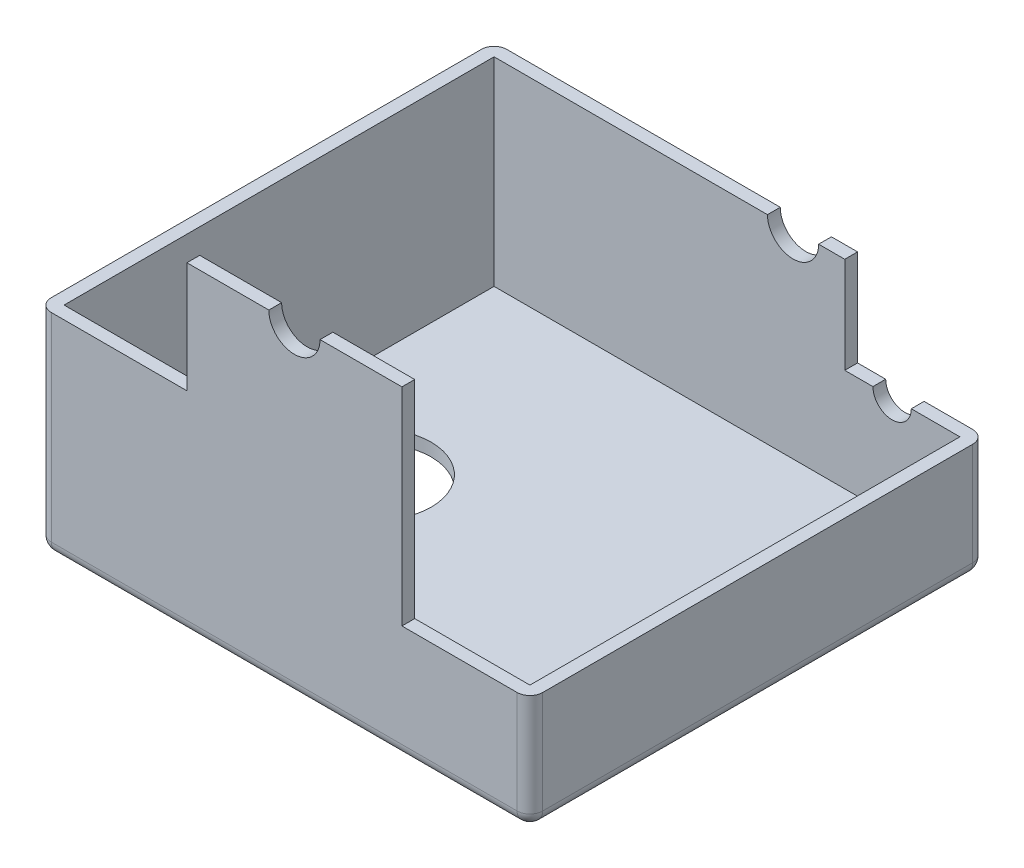
from build123d import *

# Parameters (mm, degrees)
SKETCH1_W           = 96
SKETCH1_H           = 89
BOSS_EXTRUDE1_DEPTH = 72.5
SKETCH3_W           = 91
SKETCH3_H           = 84
CUT_EXTRUDE1_DEPTH  = 70
SKETCH4_R           = 11
CUT_EXTRUDE3_DEPTH  = 10
CUT_EXTRUDE4_DEPTH  = 90
CUT_EXTRUDE5_DEPTH  = 10
SKETCH8_W           = 42
SKETCH8_H           = 21.66
BOSS_EXTRUDE2_DEPTH = 2.5
CUT_EXTRUDE6_DEPTH  = 2.5
FILLET1_R           = 2.5


with BuildPart() as part:
    # Sketch1 → Boss-Extrude1 (new body)
    with BuildSketch(Plane(origin=(0, 0, 0), x_dir=(1, 0, 0), z_dir=(0, 1, 0))):
        with Locations((48, -44.5)):
            Rectangle(SKETCH1_W, SKETCH1_H)
    extrude(amount=BOSS_EXTRUDE1_DEPTH)

    # Sketch3 → Cut-Extrude1 (cut)
    with BuildSketch(Plane(origin=(0, 72.5, 0), x_dir=(1, 0, 0), z_dir=(0, 1, 0))):
        with Locations((48, -44.5)):
            Rectangle(SKETCH3_W, SKETCH3_H)
    extrude(amount=-CUT_EXTRUDE1_DEPTH, mode=Mode.SUBTRACT)

    # Sketch4 → Cut-Extrude3 (cut)
    with BuildSketch(Plane.XZ):
        with Locations((22.7, 46)):
            Circle(SKETCH4_R)
    extrude(amount=-CUT_EXTRUDE3_DEPTH, mode=Mode.SUBTRACT)

    # Sketch6 → Cut-Extrude4 (cut, through all)
    with BuildSketch(Plane(origin=(0, 0, 0), x_dir=(-1, 0, 0), z_dir=(0, 0, -1))):
        Polygon((-96, 22.55), (-71, 22.55), (-71, 41.34), (0, 41.34), (0, 72.5), (-96, 72.5), align=None)
    extrude(amount=-CUT_EXTRUDE4_DEPTH, mode=Mode.SUBTRACT)

    # Sketch7 → Cut-Extrude5 (cut)
    with BuildSketch(Plane(origin=(0, 0, 0), x_dir=(-1, 0, 0), z_dir=(0, 0, -1))):
        with BuildLine():
            Line((-84, 22.55), (-76.5, 22.55))
            ThreePointArc((-76.5, 22.55), (-80.25, 18.8), (-84, 22.55))
        make_face()
        with BuildLine():
            Line((-65.9, 41.34), (-55.9, 41.34))
            ThreePointArc((-55.9, 41.34), (-60.9, 36.34), (-65.9, 41.34))
        make_face()
    extrude(amount=-CUT_EXTRUDE5_DEPTH, mode=Mode.SUBTRACT)

    # Sketch8 → Boss-Extrude2 (add)
    with BuildSketch(Plane.XY.offset(89)):
        with Locations((50, 52.17)):
            Rectangle(SKETCH8_W, SKETCH8_H)
    extrude(amount=-BOSS_EXTRUDE2_DEPTH)

    # Sketch9 → Cut-Extrude6 (cut)
    with BuildSketch(Plane.XY.offset(89)):
        with BuildLine():
            Line((45, 63), (55, 63))
            ThreePointArc((55, 63), (50, 58), (45, 63))
        make_face()
    extrude(amount=-CUT_EXTRUDE6_DEPTH, mode=Mode.SUBTRACT)

    # Fillet1
    fillet1_edges = [part.edges().sort_by_distance(p)[0] for p in [
        (0, 20.67, 0),
        (96, 11.275, 0),
        (96, 11.275, 89),
        (0, 20.67, 89),
        (48, 0, 0),
        (96, 0, 44.5),
        (48, 0, 89),
        (0, 0, 44.5),
    ]]
    fillet(fillet1_edges, radius=FILLET1_R)


solid = part.part
